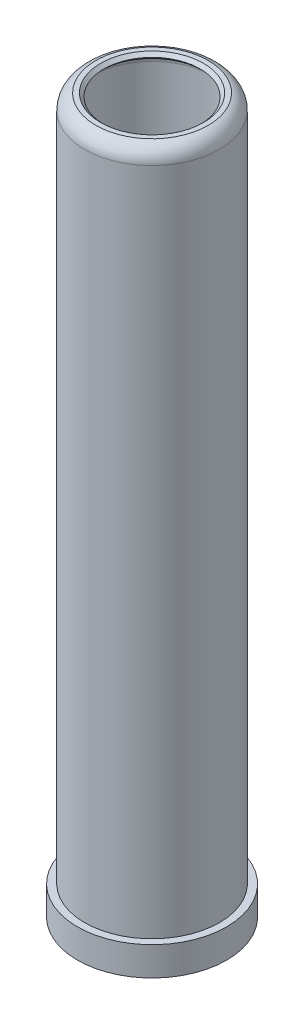
from build123d import *


with BuildPart() as part:
    # Sketch1 → Revolve1 (revolve)
    with BuildSketch(Plane.XY):
        with BuildLine():
            Line((12.5, 7), (12.5, 139.066923077))
            ThreePointArc((12.5, 139.066923077), (11.964906619, 140.358752773), (10.673076923, 140.893846154))
            Line((10.673076923, 140.893846154), (10, 141.566923077))
            Line((10, 141.566923077), (10.673076923, 142.24))
            Line((10.673076923, 142.24), (11.673076923, 142.24))
            ThreePointArc((11.673076923, 142.24), (13.355924313, 141.034344496), (14, 139.066923077))
            Line((14, 139.066923077), (14, 0))
            Line((14, 0), (15.5, 0))
            Line((15.5, 0), (15.5, -6))
            Line((15.5, -6), (14.5, -6))
            ThreePointArc((14.5, -6), (13.538055577, -2.948361096), (11, -1))
            Line((11, -1), (11, 2))
            Line((11, 2), (10, 2))
            Line((10, 2), (10, 7))
            Line((10, 7), (12.5, 7))
        make_face()
    revolve(axis=Axis((0, -1085.204253018, 0), (0, 1, 0)))


solid = part.part
